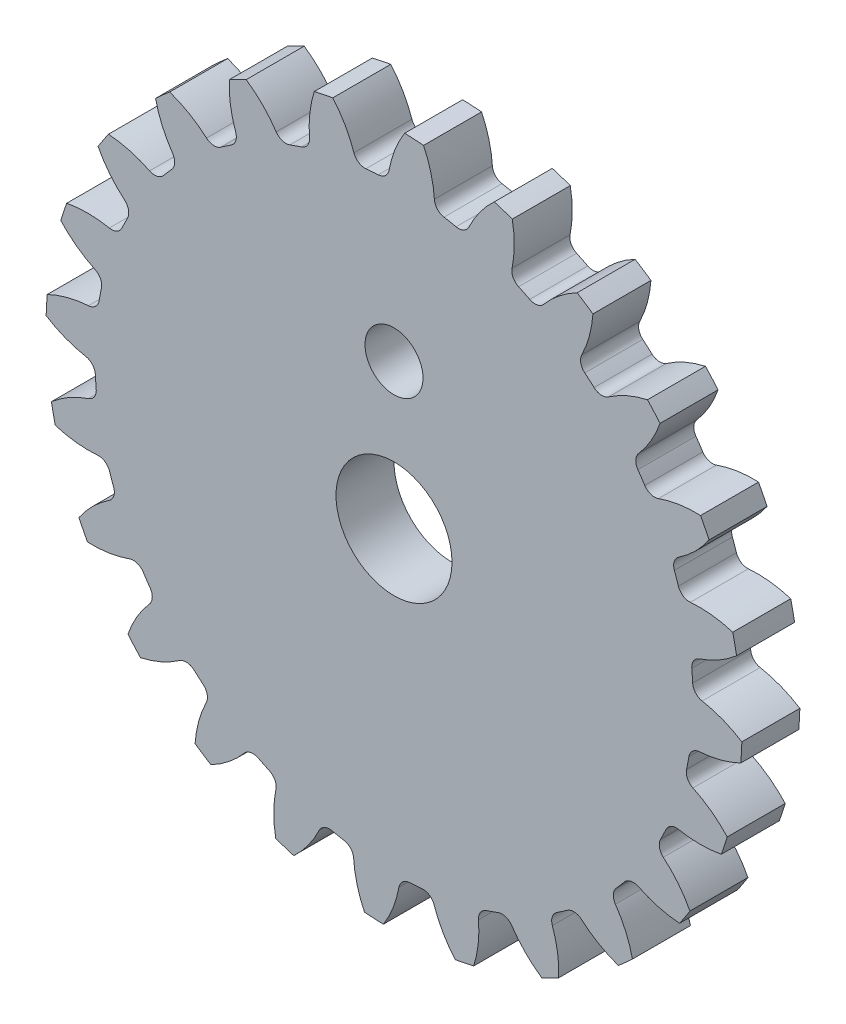
from build123d import *

# Parameters (mm, degrees)
CROQUIS1_R              = 30
SALIENTE_EXTRUIR1_DEPTH = 2.5
CORTAR_EXTRUIR1_DEPTH   = 6
MATRIZC1_COUNT          = 24
CROQUIS3_R              = 5
CROQUIS3_R_2            = 2.5
CORTAR_EXTRUIR2_DEPTH   = 6


with BuildPart() as part:
    # Croquis1 → Saliente-Extruir1 (new body, symmetric)
    with BuildSketch(Plane.XY):
        Circle(CROQUIS1_R)
    extrude(amount=SALIENTE_EXTRUIR1_DEPTH, both=True)

    # Croquis2 → Cortar-Extruir1 (cut, through all)
    with BuildSketch(Plane.XY.offset(2.5)):
        with BuildLine():
            ThreePointArc((0.915279649, 29.986034469), (-2.193162151, 29.919726599), (-5.278047422, 29.532054033))
            ThreePointArc((-5.278047422, 29.532054033), (-4.213051861, 28.025623064), (-3.455227209, 26.343585131))
            ThreePointArc((-3.455227209, 26.343585131), (-3.052028362, 25.825773823), (-2.414647226, 25.669430775))
            ThreePointArc((-2.414647226, 25.669430775), (-1.884858381, 25.713761033), (-1.354268124, 25.747158201))
            ThreePointArc((-1.354268124, 25.747158201), (-0.746497706, 25.99477278), (-0.4231156, 26.565843593))
            ThreePointArc((-0.4231156, 26.565843593), (0.081334748, 28.340408232), (0.915279649, 29.986034469))
        make_face()
    cortar_extruir1 = extrude(amount=-CORTAR_EXTRUIR1_DEPTH, mode=Mode.SUBTRACT)

    # MatrizC1: Cortar-Extruir1 ×24 about axis
    matrizc1_axis = Axis((0, 0, 0), (0, 0, 1))
    for i in range(1, MATRIZC1_COUNT):
        add(cortar_extruir1.rotate(matrizc1_axis, i * 360 / MATRIZC1_COUNT), mode=Mode.SUBTRACT)

    # Croquis3 → Cortar-Extruir2 (cut, through all)
    with BuildSketch(Plane.XY.offset(2.5)):
        Circle(CROQUIS3_R)
        with Locations((0, 12.5)):
            Circle(CROQUIS3_R_2)
    extrude(amount=-CORTAR_EXTRUIR2_DEPTH, mode=Mode.SUBTRACT)


solid = part.part
